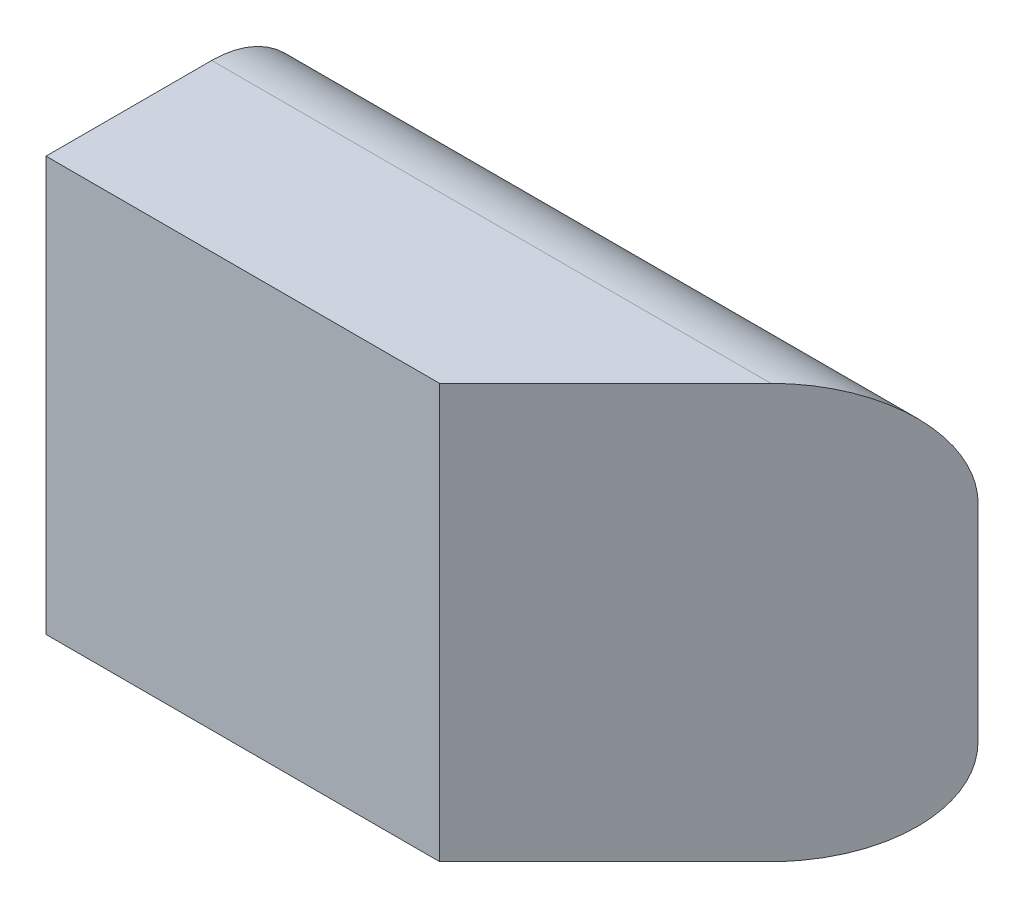
from build123d import *

# Parameters (mm, degrees)
BOSS_EXTRUDE1_DEPTH = 203.2
SKETCH2_W           = 344.402501539
SKETCH2_H           = 780.457540957
CUT_EXTRUDE1_DEPTH  = 59.371664787


with BuildPart() as part:
    # Sketch1 → Boss-Extrude1 (new body)
    with BuildSketch(Plane(origin=(0, 0, 0), x_dir=(0, 0, -1), z_dir=(1, 0, 0))):
        with BuildLine():
            Line((0, 0), (31.75, 0))
            ThreePointArc((31.75, 0), (54.200640303, 9.299359697), (63.5, 31.75))
            Line((63.5, 31.75), (63.5, 95.25))
            ThreePointArc((63.5, 95.25), (54.200640303, 117.700640303), (31.75, 127))
            Line((31.75, 127), (0, 127))
            Line((0, 127), (-19.05, 127))
            Line((-19.05, 127), (-19.05, 0))
            Line((-19.05, 0), (0, 0))
        make_face()
    extrude(amount=BOSS_EXTRUDE1_DEPTH)

    # Sketch2 → Cut-Extrude1 (cut, through all)
    with BuildSketch(Plane(origin=(69.85, 0, 69.85), x_dir=(0, 1, 0), z_dir=(0.707106781, 0, 0.707106781))):
        with Locations((32.995160032, -188.585378543)):
            Rectangle(SKETCH2_W, SKETCH2_H)
    extrude(amount=CUT_EXTRUDE1_DEPTH, mode=Mode.SUBTRACT)


solid = part.part
